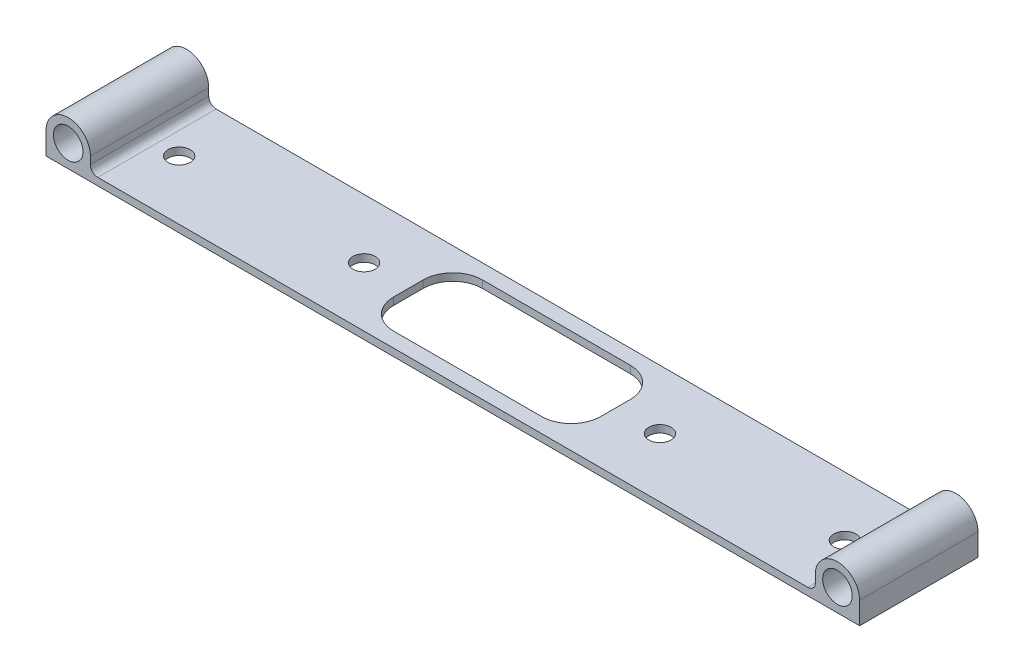
from build123d import *

# Parameters (mm, degrees)
SKETCH1_R           = 6.35
BOSS_EXTRUDE1_DEPTH = 50.8
SKETCH6_R           = 4.7625
CUT_EXTRUDE3_DEPTH  = 12.7
SKETCH7_W           = 88.9
SKETCH7_H           = 38.1
CUT_EXTRUDE4_DEPTH  = 4.175
FILLET1_R           = 12.7
FILLET2_R           = 3.175


with BuildPart() as part:
    # Sketch1 → Boss-Extrude1 (new body)
    with BuildSketch(Plane.XY):
        with BuildLine():
            ThreePointArc((9.525, 0), (0, 9.525), (-9.525, 0))
            Line((-9.525, 0), (-9.525, -9.525))
            Line((-9.525, -9.525), (165.1, -9.525))
            Line((165.1, -9.525), (165.1, -6.35))
            Line((165.1, -6.35), (9.525, -6.35))
            Line((9.525, -6.35), (9.525, 0))
        make_face()
        Circle(SKETCH1_R, mode=Mode.SUBTRACT)
    boss_extrude1 = extrude(amount=BOSS_EXTRUDE1_DEPTH)

    # Sketch6 → Cut-Extrude3 (cut)
    with BuildSketch(Plane(origin=(0, -6.35, 0), x_dir=(1, 0, 0), z_dir=(0, 1, 0))):
        with Locations((22.225, -25.4)):
            Circle(SKETCH6_R)
        with Locations((101.6, -25.4)):
            Circle(SKETCH6_R)
    cut_extrude3 = extrude(amount=-CUT_EXTRUDE3_DEPTH, mode=Mode.SUBTRACT)

    # Mirror1: Boss-Extrude1, Cut-Extrude3 across plane
    add(boss_extrude1.mirror(Plane(origin=(165.1, 0, 50.8), x_dir=(0, 0, 1), z_dir=(1, 0, 0))))
    add(cut_extrude3.mirror(Plane(origin=(165.1, 0, 50.8), x_dir=(0, 0, 1), z_dir=(1, 0, 0))), mode=Mode.SUBTRACT)

    # Sketch7 → Cut-Extrude4 (cut, through all)
    with BuildSketch(Plane(origin=(0, -6.35, 0), x_dir=(1, 0, 0), z_dir=(0, 1, 0))):
        with Locations((165.1, -25.4)):
            Rectangle(SKETCH7_W, SKETCH7_H)
    extrude(amount=-CUT_EXTRUDE4_DEPTH, mode=Mode.SUBTRACT)

    # Fillet1
    fillet1_edges = [part.edges().sort_by_distance(p)[0] for p in [
        (120.65, -7.9375, 44.45),
        (120.65, -7.9375, 6.35),
        (209.55, -7.9375, 6.35),
        (209.55, -7.9375, 44.45),
    ]]
    fillet(fillet1_edges, radius=FILLET1_R)

    # Fillet2
    fillet2_edges = [part.edges().sort_by_distance(p)[0] for p in [
        (9.525, -6.35, 25.4),
        (320.675, -6.35, 25.4),
    ]]
    fillet(fillet2_edges, radius=FILLET2_R)


solid = part.part
